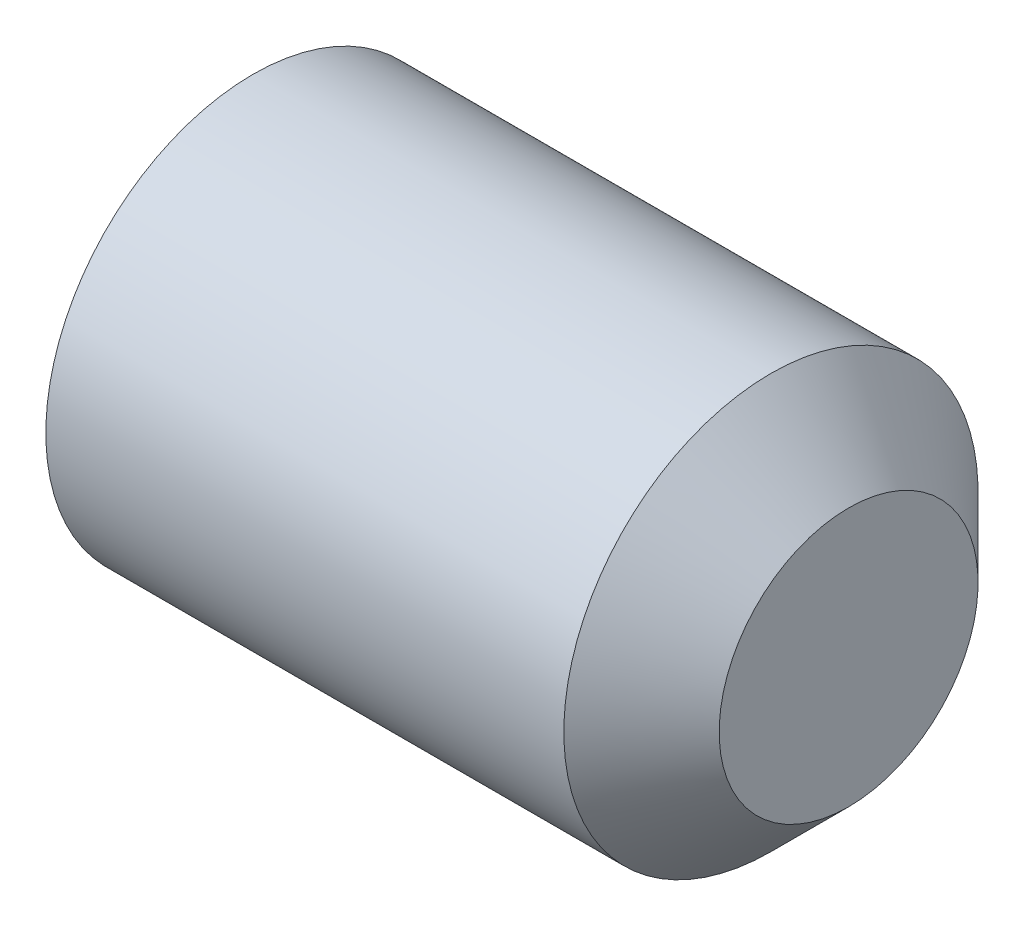
from build123d import *

# Parameters (mm, degrees)
CUT_EXTRUDE_1_DEPTH = 2.5


with BuildPart() as part:
    # 草图1 → 旋转1 (revolve)
    with BuildSketch(Plane.XY):
        Polygon((6, 0), (6, -1.25), (5.25, -2), (0.247971941, -2), (0, -1.5705), (0, -1.154700538), (0.666666667, 0), align=None)
    revolve(axis=Axis((0.666666667, 0, 0), (1, 0, 0)))

    # 草图2 → 切除-拉伸1 (cut)
    with BuildSketch(Plane(origin=(0, 0, 0), x_dir=(0, 0, -1), z_dir=(1, 0, 0))):
        Polygon((-1.154700538, 0), (-0.577350269, -1), (0.577350269, -1), (1.154700538, 0), (0.577350269, 1), (-0.577350269, 1), align=None)
    extrude(amount=CUT_EXTRUDE_1_DEPTH, mode=Mode.SUBTRACT)


solid = part.part
